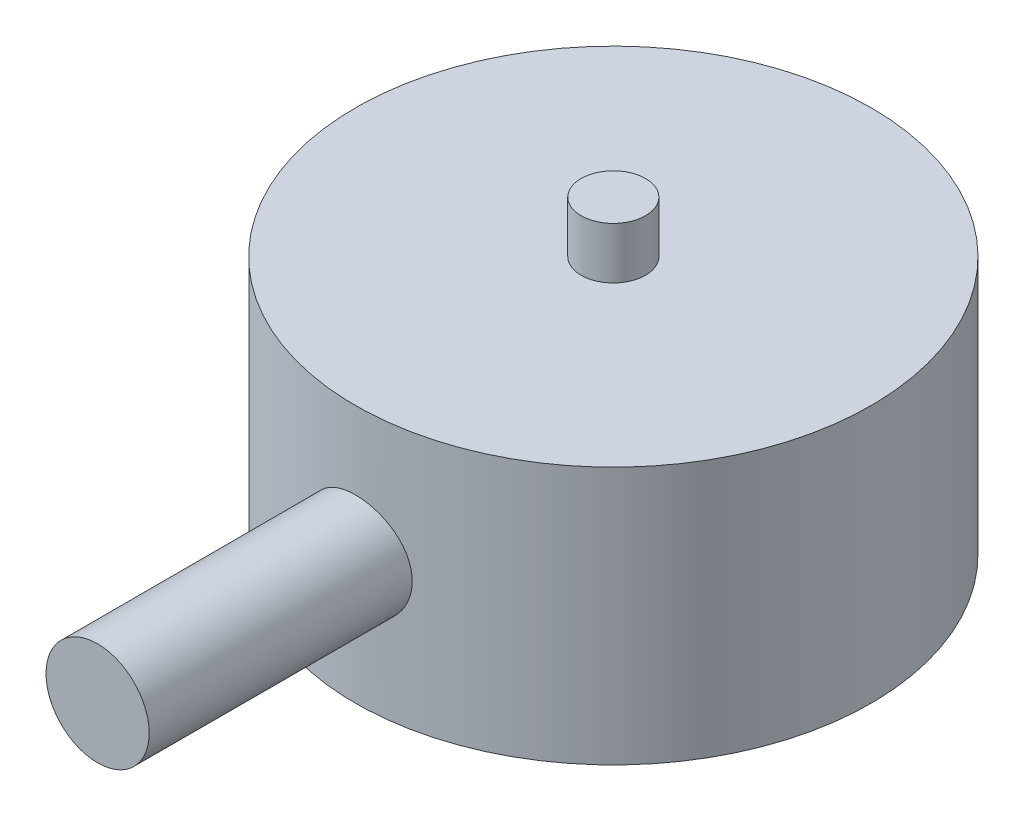
from build123d import *

# Parameters (mm, degrees)
SKETCH2_R           = 2
BOSS_EXTRUDE1_DEPTH = 20


with BuildPart() as part:
    # Sketch1 → Revolve1 (revolve)
    with BuildSketch(Plane.XY):
        Polygon((0, 0), (0, -12), (10, -12), (10, -2), (1.25, -2), (1.25, 0), align=None)
    revolve(axis=Axis((0, 0, 0), (0, 1, 0)))

    # Sketch2 → Boss-Extrude1 (add)
    with BuildSketch(Plane.XY):
        with Locations((0, -7)):
            Circle(SKETCH2_R)
    extrude(amount=BOSS_EXTRUDE1_DEPTH)


solid = part.part
